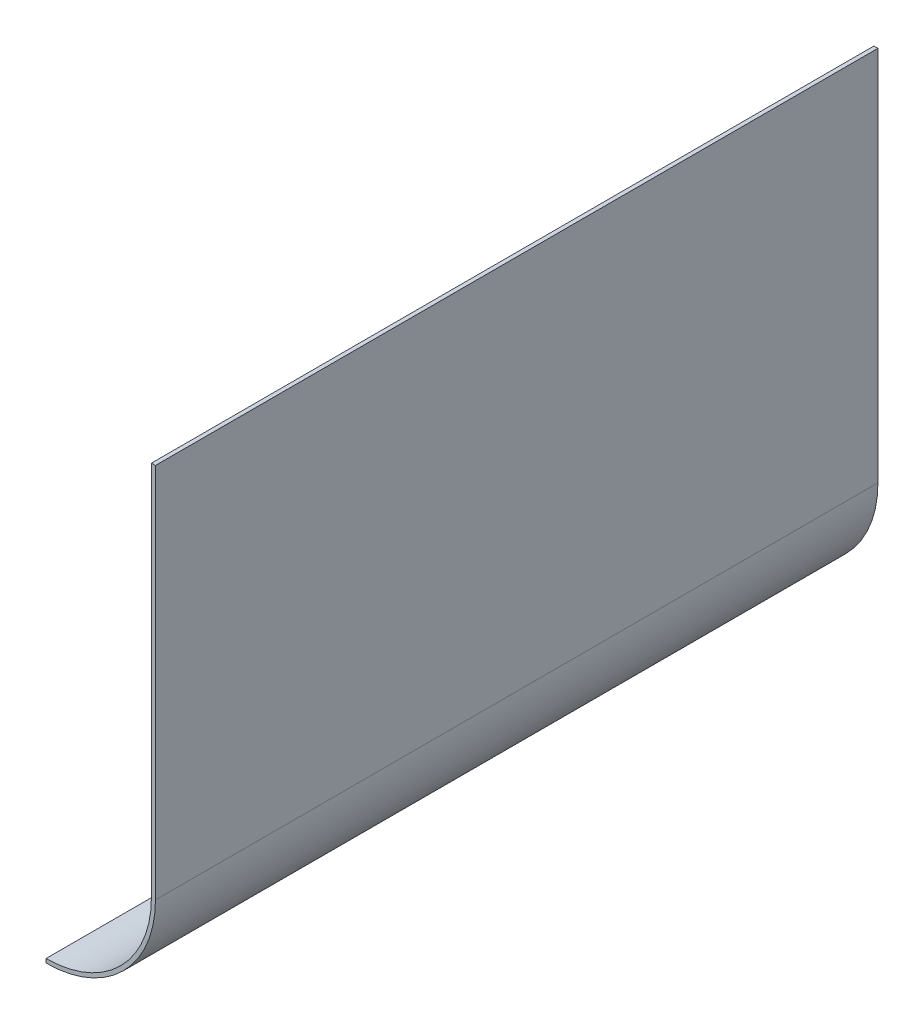
from build123d import *

# Parameters (mm, degrees)
EXTRUDE_THIN1_DEPTH = 457.2


with BuildPart() as part:
    # Sketch1 → Extrude-Thin1 (new body)
    with BuildSketch(Plane.XY):
        with BuildLine():
            Line((66.675, 238.125), (66.675, 0))
            ThreePointArc((66.675, 0), (47.146344636, -47.146344636), (0, -66.675))
            Line((0, -66.675), (0, -69.215))
            ThreePointArc((0, -69.215), (48.94239586, -48.94239586), (69.215, 0))
            Line((69.215, 0), (69.215, 238.125))
            Line((69.215, 238.125), (66.675, 238.125))
        make_face()
    extrude(amount=EXTRUDE_THIN1_DEPTH)


solid = part.part
